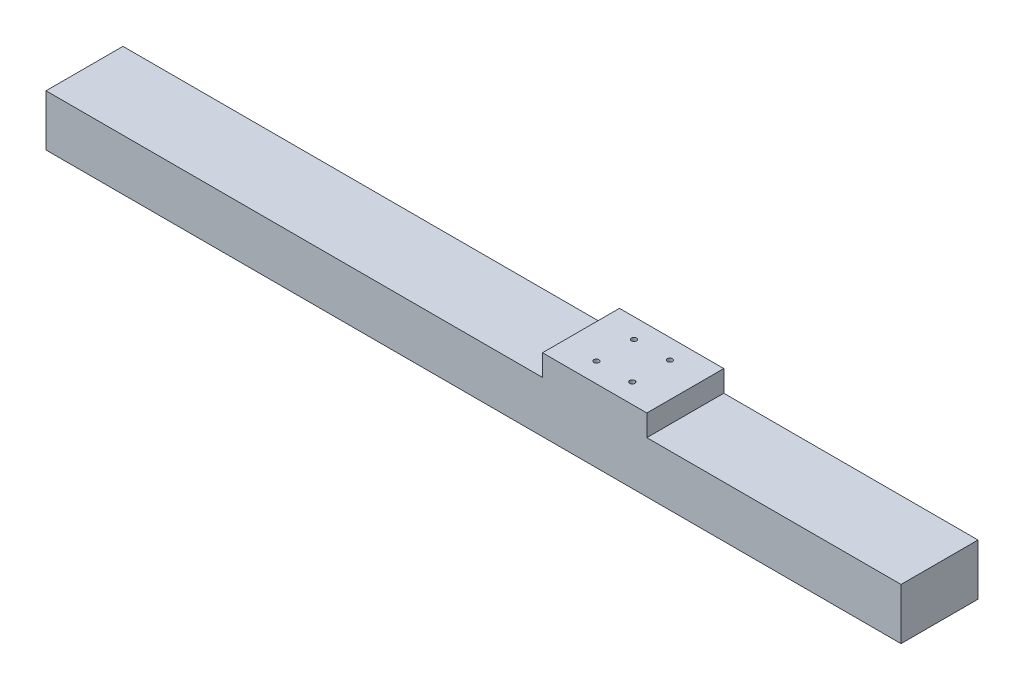
from build123d import *

# Parameters (mm, degrees)
SKETCH1_W           = 1000
SKETCH1_H           = 90
BOSS_EXTRUDE1_DEPTH = 60
SKETCH2_W           = 122
SKETCH2_H           = 90
BOSS_EXTRUDE2_DEPTH = 25
SKETCH3_R           = 3
CUT_EXTRUDE1_DEPTH  = 10


with BuildPart() as part:
    # Sketch1 → Boss-Extrude1 (new body)
    with BuildSketch(Plane(origin=(0, 0, 0), x_dir=(1, 0, 0), z_dir=(0, 1, 0))):
        with Locations((374.694533762, -45)):
            Rectangle(SKETCH1_W, SKETCH1_H)
    extrude(amount=BOSS_EXTRUDE1_DEPTH)

    # Sketch2 → Boss-Extrude2 (add)
    with BuildSketch(Plane(origin=(0, 60, 0), x_dir=(1, 0, 0), z_dir=(0, 1, 0))):
        with Locations((516.382198595, -45)):
            Rectangle(SKETCH2_W, SKETCH2_H)
    extrude(amount=BOSS_EXTRUDE2_DEPTH)

    # Sketch3 → Cut-Extrude1 (cut)
    with BuildSketch(Plane(origin=(0, 85, 0), x_dir=(1, 0, 0), z_dir=(0, 1, 0))):
        with Locations((495.382198595, -23)):
            Circle(SKETCH3_R)
        with Locations((537.382198595, -23)):
            Circle(SKETCH3_R)
        with Locations((537.382198595, -67)):
            Circle(SKETCH3_R)
        with Locations((495.382198595, -67)):
            Circle(SKETCH3_R)
    extrude(amount=-CUT_EXTRUDE1_DEPTH, mode=Mode.SUBTRACT)


solid = part.part
